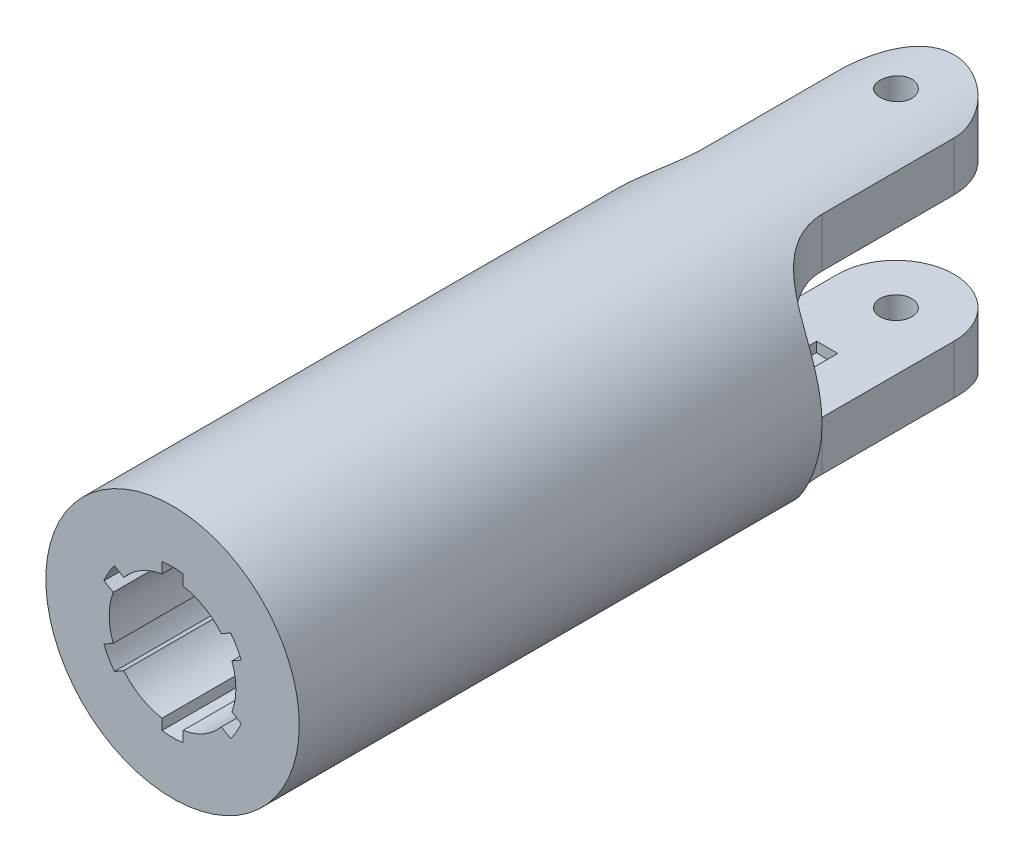
from build123d import *

# Parameters (mm, degrees)
SKETCH_1_R          = 6
SKETCH_1_R_2        = 2.5
EXTRUDE_1_DEPTH     = 37
SKETCH_2_OUTSIDE_W  = 22.142
SKETCH_2_OUTSIDE_H  = 47.142
SKETCH_2_OUTSIDE_R  = 0.75
CUT_EXTRUDE_1_DEPTH = 9.5
CUT_EXTRUDE_2_DEPTH = 9.5
CUT_EXTRUDE_3_DEPTH = 31


with BuildPart() as part:
    # 草图1 → 凸台-拉伸1 (new body)
    with BuildSketch(Plane.XY):
        Circle(SKETCH_1_R)
        Circle(SKETCH_1_R_2, mode=Mode.SUBTRACT)
    extrude(amount=EXTRUDE_1_DEPTH)

    # 草图2 outside → 切除-拉伸1 (cut, symmetric)
    with BuildSketch(Plane(origin=(0, 0, 0), x_dir=(1, 0, 0), z_dir=(0, 1, 0))):
        with Locations((0, -18.5)):
            Rectangle(SKETCH_2_OUTSIDE_W, SKETCH_2_OUTSIDE_H)
        with BuildLine():
            Line((-2.75, -2.75), (-2.75, -9))
            ThreePointArc((-2.75, -9), (-3.701902961, -11.298097039), (-6, -12.25))
            Line((-6, -12.25), (-6, -37))
            Line((-6, -37), (6, -37))
            Line((6, -37), (6, -12.25))
            ThreePointArc((6, -12.25), (3.701902961, -11.298097039), (2.75, -9))
            Line((2.75, -9), (2.75, -2.75))
            ThreePointArc((2.75, -2.75), (0, 0), (-2.75, -2.75))
        make_face(mode=Mode.SUBTRACT)
        with Locations((0, -2.75)):
            Circle(SKETCH_2_OUTSIDE_R)
    extrude(amount=CUT_EXTRUDE_1_DEPTH, both=True, mode=Mode.SUBTRACT)

    # 草图3 → 切除-拉伸2 (cut, symmetric)
    with BuildSketch(Plane(origin=(0, 0, 0), x_dir=(0, 0, -1), z_dir=(1, 0, 0))):
        with BuildLine():
            Line((-9.250000001, 3), (0.966464558, 3))
            Line((0.966464558, 3), (0.966464558, -3))
            Line((0.966464558, -3), (-9.250000001, -3))
            ThreePointArc((-9.250000001, -3), (-12.250000001, 0), (-9.250000001, 3))
        make_face()
    extrude(amount=CUT_EXTRUDE_2_DEPTH, both=True, mode=Mode.SUBTRACT)

    # 草图4 → 切除-拉伸3 (cut)
    with BuildSketch(Plane.XY.offset(37)):
        with BuildLine():
            Line((-0.5, 3.464101615), (-0.5, 2.958039892))
            ThreePointArc((-0.5, 2.958039892), (-1.5, 2.598076211), (-2.311737691, 1.912032648))
            Line((-2.311737691, 1.912032648), (-2.75, 2.165063509))
            ThreePointArc((-2.75, 2.165063509), (-3.031088913, 1.75), (-3.25, 1.299038106))
            Line((-3.25, 1.299038106), (-2.811737691, 1.046007244))
            ThreePointArc((-2.811737691, 1.046007244), (-3, 0), (-2.811737691, -1.046007244))
            Line((-2.811737691, -1.046007244), (-3.25, -1.299038106))
            ThreePointArc((-3.25, -1.299038106), (-3.031088913, -1.75), (-2.75, -2.165063509))
            Line((-2.75, -2.165063509), (-2.311737691, -1.912032648))
            ThreePointArc((-2.311737691, -1.912032648), (-1.5, -2.598076211), (-0.5, -2.958039892))
            Line((-0.5, -2.958039892), (-0.5, -3.464101615))
            ThreePointArc((-0.5, -3.464101615), (0, -3.5), (0.5, -3.464101615))
            Line((0.5, -3.464101615), (0.5, -2.958039892))
            ThreePointArc((0.5, -2.958039892), (1.5, -2.598076211), (2.311737691, -1.912032648))
            Line((2.311737691, -1.912032648), (2.75, -2.165063509))
            ThreePointArc((2.75, -2.165063509), (3.031088913, -1.75), (3.25, -1.299038106))
            Line((3.25, -1.299038106), (2.811737691, -1.046007244))
            ThreePointArc((2.811737691, -1.046007244), (3, 0), (2.811737691, 1.046007244))
            Line((2.811737691, 1.046007244), (3.25, 1.299038106))
            ThreePointArc((3.25, 1.299038106), (3.031088913, 1.75), (2.75, 2.165063509))
            Line((2.75, 2.165063509), (2.311737691, 1.912032648))
            ThreePointArc((2.311737691, 1.912032648), (1.5, 2.598076211), (0.5, 2.958039892))
            Line((0.5, 2.958039892), (0.5, 3.464101615))
            ThreePointArc((0.5, 3.464101615), (0, 3.5), (-0.5, 3.464101615))
        make_face()
    extrude(amount=-CUT_EXTRUDE_3_DEPTH, mode=Mode.SUBTRACT)


solid = part.part
